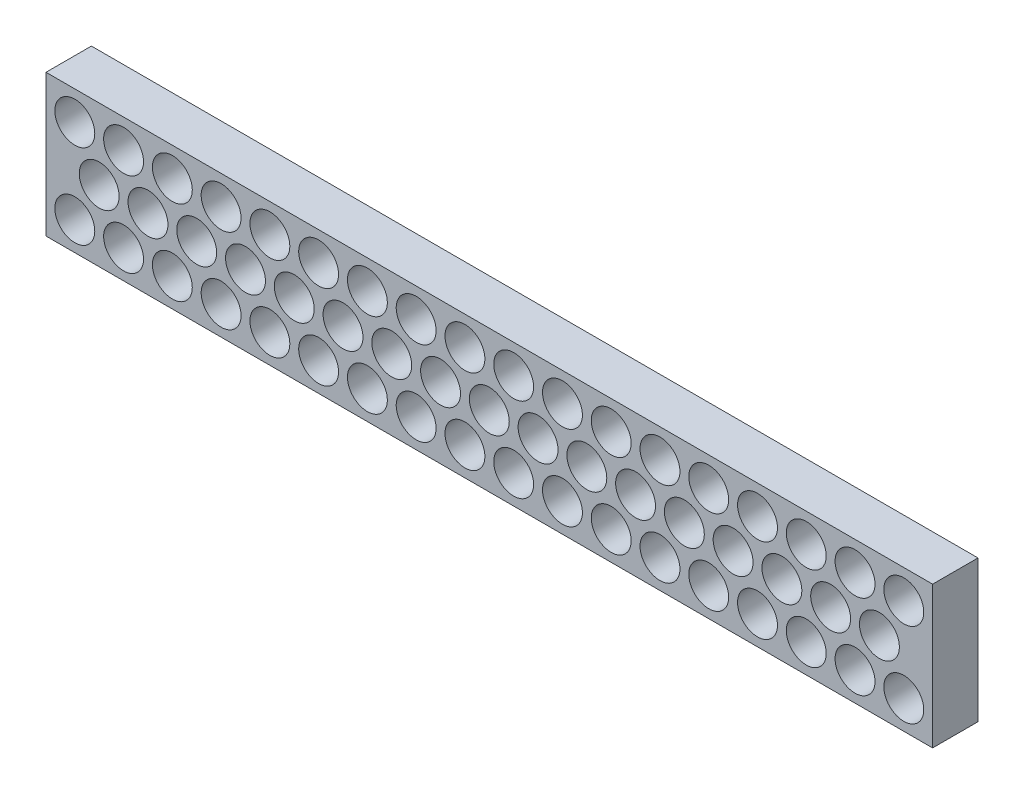
from build123d import *

# Parameters (mm, degrees)
SKETCH1_W               = 635
SKETCH1_H               = 101.6
BOSS_EXTRUDE1_DEPTH     = 32.512
SKETCH1_3_R             = 14.2875
CUT_EXTRUDE2_DEPTH      = 600.94650035
LPATTERN1_COUNT         = 17
LPATTERN1_PITCH         = 34.925
CUT_EXTRUDE3_DEPTH      = 600.94650035
CUT_EXTRUDE3_DEPTH_BACK = 600.94650035
SKETCH3_R               = 14.2875


with BuildPart() as part:
    # Sketch1 → Boss-Extrude1 (new body)
    with BuildSketch(Plane.XY):
        with Locations((-279.4, 0.08382)):
            Rectangle(SKETCH1_W, SKETCH1_H)
    extrude(amount=-BOSS_EXTRUDE1_DEPTH)

    # Sketch1_3 → Cut-Extrude2 (cut, symmetric)
    with BuildSketch(Plane.XY):
        Circle(SKETCH1_3_R)
        with Locations((17.4625, 30.24632)):
            Circle(SKETCH1_3_R)
        with Locations((17.4625, -30.24632)):
            Circle(SKETCH1_3_R)
    cut_extrude2 = extrude(amount=CUT_EXTRUDE2_DEPTH, both=True, mode=Mode.SUBTRACT)

    # LPattern1: Cut-Extrude2 ×17
    with Locations(*[(-i * LPATTERN1_PITCH, 0, 0) for i in range(1, LPATTERN1_COUNT)]):
        add(cut_extrude2, mode=Mode.SUBTRACT)

    # Sketch3 → Cut-Extrude3 (cut, two sides: drawn at the far end of the back side and taken through both)
    with BuildSketch(Plane.XY.offset(-CUT_EXTRUDE3_DEPTH_BACK)):
        with Locations((-576.2625, 30.24632)):
            Circle(SKETCH3_R)
        with Locations((-576.2625, -30.24632)):
            Circle(SKETCH3_R)
    extrude(amount=CUT_EXTRUDE3_DEPTH + CUT_EXTRUDE3_DEPTH_BACK, mode=Mode.SUBTRACT)


solid = part.part
